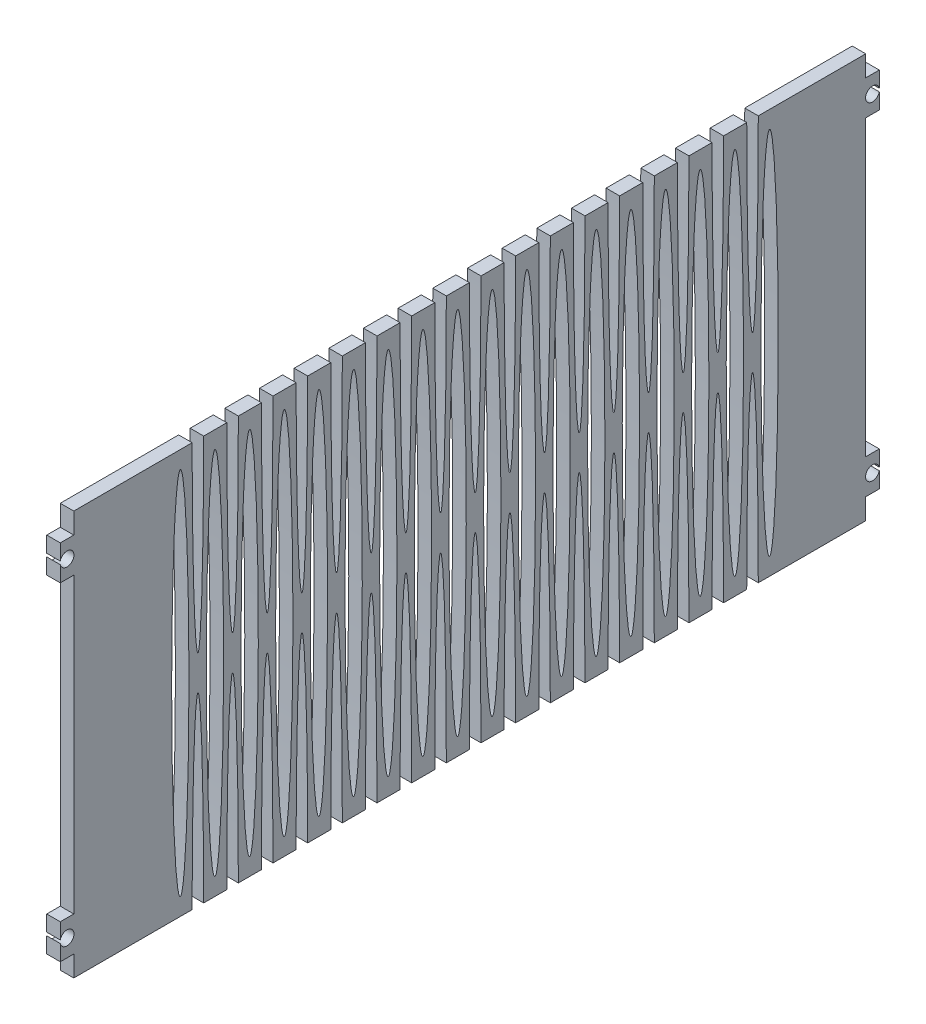
from build123d import *

# Parameters (mm, degrees)
SKETCH2_W             = 198.12
SKETCH2_H             = 88.9
BOSS_EXTRUDE1_DEPTH   = 2.9718
SKETCH3_RX            = 40.64
SKETCH3_RY            = 1.905
CUT_EXTRUDE1_DEPTH    = 3.9718
LPATTERN1_COUNT       = 18
LPATTERN1_PITCH       = 7.62
CUT_EXTRUDE2_DEPTH    = 3.9718001
LPATTERN2_COUNT       = 17
LPATTERN2_PITCH       = 7.62
MIRROR1_COPY_1_DEPTH  = 3.9718001
MIRROR1_COPY_2_DEPTH  = 3.9718001
MIRROR1_COPY_3_DEPTH  = 3.9718001
MIRROR1_COPY_4_DEPTH  = 3.9718001
MIRROR1_COPY_5_DEPTH  = 3.9718001
MIRROR1_COPY_6_DEPTH  = 3.9718001
MIRROR1_COPY_7_DEPTH  = 3.9718001
MIRROR1_COPY_8_DEPTH  = 3.9718001
MIRROR1_COPY_9_DEPTH  = 3.9718001
MIRROR1_COPY_10_DEPTH = 3.9718001
MIRROR1_COPY_11_DEPTH = 3.9718001
MIRROR1_COPY_12_DEPTH = 3.9718001
MIRROR1_COPY_13_DEPTH = 3.9718001
MIRROR1_COPY_14_DEPTH = 3.9718001
MIRROR1_COPY_15_DEPTH = 3.9718001
MIRROR1_COPY_16_DEPTH = 3.9718001
SKETCH5_W             = 48.694690428
SKETCH5_H             = 116.446098742
CUT_EXTRUDE3_DEPTH    = 3.9718001
SKETCH7_W             = 2.9718
SKETCH7_H             = 7.62
BOSS_EXTRUDE2_DEPTH   = 2.9718
SKETCH8_R             = 1.524
CUT_EXTRUDE4_DEPTH    = 3.9718001


with BuildPart() as part:
    # Sketch2 → Boss-Extrude1 (new body)
    with BuildSketch(Plane(origin=(0, 0, 0), x_dir=(0, 0, -1), z_dir=(1, 0, 0))):
        with Locations((99.06, 0)):
            Rectangle(SKETCH2_W, SKETCH2_H)
    extrude(amount=BOSS_EXTRUDE1_DEPTH)

    # Sketch3 → Cut-Extrude1 (cut, through all)
    with BuildSketch(Plane(origin=(2.9718, 0, 0), x_dir=(0, 0, -1), z_dir=(1, 0, 0))):
        with Locations(Location((47.434047001, 0), (0, 0, 90))):
            Ellipse(SKETCH3_RX, SKETCH3_RY)
    cut_extrude1 = extrude(amount=-CUT_EXTRUDE1_DEPTH, mode=Mode.SUBTRACT)

    # LPattern1: Cut-Extrude1 ×18
    with Locations(*[(0, 0, -i * LPATTERN1_PITCH) for i in range(1, LPATTERN1_COUNT)]):
        add(cut_extrude1, mode=Mode.SUBTRACT)

    # Sketch4 → Cut-Extrude2 (cut, through all)
    with BuildSketch(Plane(origin=(2.9718, 0, 0), x_dir=(0, 0, -1), z_dir=(1, 0, 0))):
        with BuildLine():
            Line((50.038, -44.45), (52.578, -44.45))
            add(Edge.make_bspline(
                [(52.578, -44.45), (52.578, -3.81), (51.308, -3.81), (50.038, -3.81), (50.038, -44.45)],
                knots=[4.71238898, 4.71238898, 4.71238898, 6.283185307, 6.283185307, 7.853981634, 7.853981634, 7.853981634], degree=2, weights=[1, 0.707106781, 1, 0.707106781, 1]))
        make_face()
    cut_extrude2 = extrude(amount=-CUT_EXTRUDE2_DEPTH, mode=Mode.SUBTRACT)

    # LPattern2: Cut-Extrude2 ×17
    with Locations(*[(0, 0, -i * LPATTERN2_PITCH) for i in range(1, LPATTERN2_COUNT)]):
        add(cut_extrude2, mode=Mode.SUBTRACT)

    # Mirror1: Cut-Extrude2 across plane
    add(cut_extrude2.mirror(Plane.ZX), mode=Mode.SUBTRACT)

    # Mirror1 copy 1 sketch → Mirror1 copy 1 (cut, through all)
    with BuildSketch(Plane(origin=(2.9718, 0, -7.62), x_dir=(0, 0, -1), z_dir=(1, 0, 0))):
        with BuildLine():
            Line((50.038, 44.45), (52.578, 44.45))
            add(Edge.make_bspline(
                [(52.578, 44.45), (52.578, 3.81), (51.308, 3.81), (50.038, 3.81), (50.038, 44.45)],
                knots=[4.71238898, 4.71238898, 4.71238898, 6.283185307, 6.283185307, 7.853981634, 7.853981634, 7.853981634], degree=2, weights=[1, 0.707106781, 1, 0.707106781, 1]))
        make_face()
    extrude(amount=-MIRROR1_COPY_1_DEPTH, mode=Mode.SUBTRACT)

    # Mirror1 copy 2 sketch → Mirror1 copy 2 (cut, through all)
    with BuildSketch(Plane(origin=(2.9718, 0, -15.24), x_dir=(0, 0, -1), z_dir=(1, 0, 0))):
        with BuildLine():
            Line((50.038, 44.45), (52.578, 44.45))
            add(Edge.make_bspline(
                [(52.578, 44.45), (52.578, 3.81), (51.308, 3.81), (50.038, 3.81), (50.038, 44.45)],
                knots=[4.71238898, 4.71238898, 4.71238898, 6.283185307, 6.283185307, 7.853981634, 7.853981634, 7.853981634], degree=2, weights=[1, 0.707106781, 1, 0.707106781, 1]))
        make_face()
    extrude(amount=-MIRROR1_COPY_2_DEPTH, mode=Mode.SUBTRACT)

    # Mirror1 copy 3 sketch → Mirror1 copy 3 (cut, through all)
    with BuildSketch(Plane(origin=(2.9718, 0, -22.86), x_dir=(0, 0, -1), z_dir=(1, 0, 0))):
        with BuildLine():
            Line((50.038, 44.45), (52.578, 44.45))
            add(Edge.make_bspline(
                [(52.578, 44.45), (52.578, 3.81), (51.308, 3.81), (50.038, 3.81), (50.038, 44.45)],
                knots=[4.71238898, 4.71238898, 4.71238898, 6.283185307, 6.283185307, 7.853981634, 7.853981634, 7.853981634], degree=2, weights=[1, 0.707106781, 1, 0.707106781, 1]))
        make_face()
    extrude(amount=-MIRROR1_COPY_3_DEPTH, mode=Mode.SUBTRACT)

    # Mirror1 copy 4 sketch → Mirror1 copy 4 (cut, through all)
    with BuildSketch(Plane(origin=(2.9718, 0, -30.48), x_dir=(0, 0, -1), z_dir=(1, 0, 0))):
        with BuildLine():
            Line((50.038, 44.45), (52.578, 44.45))
            add(Edge.make_bspline(
                [(52.578, 44.45), (52.578, 3.81), (51.308, 3.81), (50.038, 3.81), (50.038, 44.45)],
                knots=[4.71238898, 4.71238898, 4.71238898, 6.283185307, 6.283185307, 7.853981634, 7.853981634, 7.853981634], degree=2, weights=[1, 0.707106781, 1, 0.707106781, 1]))
        make_face()
    extrude(amount=-MIRROR1_COPY_4_DEPTH, mode=Mode.SUBTRACT)

    # Mirror1 copy 5 sketch → Mirror1 copy 5 (cut, through all)
    with BuildSketch(Plane(origin=(2.9718, 0, -38.1), x_dir=(0, 0, -1), z_dir=(1, 0, 0))):
        with BuildLine():
            Line((50.038, 44.45), (52.578, 44.45))
            add(Edge.make_bspline(
                [(52.578, 44.45), (52.578, 3.81), (51.308, 3.81), (50.038, 3.81), (50.038, 44.45)],
                knots=[4.71238898, 4.71238898, 4.71238898, 6.283185307, 6.283185307, 7.853981634, 7.853981634, 7.853981634], degree=2, weights=[1, 0.707106781, 1, 0.707106781, 1]))
        make_face()
    extrude(amount=-MIRROR1_COPY_5_DEPTH, mode=Mode.SUBTRACT)

    # Mirror1 copy 6 sketch → Mirror1 copy 6 (cut, through all)
    with BuildSketch(Plane(origin=(2.9718, 0, -45.72), x_dir=(0, 0, -1), z_dir=(1, 0, 0))):
        with BuildLine():
            Line((50.038, 44.45), (52.578, 44.45))
            add(Edge.make_bspline(
                [(52.578, 44.45), (52.578, 3.81), (51.308, 3.81), (50.038, 3.81), (50.038, 44.45)],
                knots=[4.71238898, 4.71238898, 4.71238898, 6.283185307, 6.283185307, 7.853981634, 7.853981634, 7.853981634], degree=2, weights=[1, 0.707106781, 1, 0.707106781, 1]))
        make_face()
    extrude(amount=-MIRROR1_COPY_6_DEPTH, mode=Mode.SUBTRACT)

    # Mirror1 copy 7 sketch → Mirror1 copy 7 (cut, through all)
    with BuildSketch(Plane(origin=(2.9718, 0, -53.34), x_dir=(0, 0, -1), z_dir=(1, 0, 0))):
        with BuildLine():
            Line((50.038, 44.45), (52.578, 44.45))
            add(Edge.make_bspline(
                [(52.578, 44.45), (52.578, 3.81), (51.308, 3.81), (50.038, 3.81), (50.038, 44.45)],
                knots=[4.71238898, 4.71238898, 4.71238898, 6.283185307, 6.283185307, 7.853981634, 7.853981634, 7.853981634], degree=2, weights=[1, 0.707106781, 1, 0.707106781, 1]))
        make_face()
    extrude(amount=-MIRROR1_COPY_7_DEPTH, mode=Mode.SUBTRACT)

    # Mirror1 copy 8 sketch → Mirror1 copy 8 (cut, through all)
    with BuildSketch(Plane(origin=(2.9718, 0, -60.96), x_dir=(0, 0, -1), z_dir=(1, 0, 0))):
        with BuildLine():
            Line((50.038, 44.45), (52.578, 44.45))
            add(Edge.make_bspline(
                [(52.578, 44.45), (52.578, 3.81), (51.308, 3.81), (50.038, 3.81), (50.038, 44.45)],
                knots=[4.71238898, 4.71238898, 4.71238898, 6.283185307, 6.283185307, 7.853981634, 7.853981634, 7.853981634], degree=2, weights=[1, 0.707106781, 1, 0.707106781, 1]))
        make_face()
    extrude(amount=-MIRROR1_COPY_8_DEPTH, mode=Mode.SUBTRACT)

    # Mirror1 copy 9 sketch → Mirror1 copy 9 (cut, through all)
    with BuildSketch(Plane(origin=(2.9718, 0, -68.58), x_dir=(0, 0, -1), z_dir=(1, 0, 0))):
        with BuildLine():
            Line((50.038, 44.45), (52.578, 44.45))
            add(Edge.make_bspline(
                [(52.578, 44.45), (52.578, 3.81), (51.308, 3.81), (50.038, 3.81), (50.038, 44.45)],
                knots=[4.71238898, 4.71238898, 4.71238898, 6.283185307, 6.283185307, 7.853981634, 7.853981634, 7.853981634], degree=2, weights=[1, 0.707106781, 1, 0.707106781, 1]))
        make_face()
    extrude(amount=-MIRROR1_COPY_9_DEPTH, mode=Mode.SUBTRACT)

    # Mirror1 copy 10 sketch → Mirror1 copy 10 (cut, through all)
    with BuildSketch(Plane(origin=(2.9718, 0, -76.2), x_dir=(0, 0, -1), z_dir=(1, 0, 0))):
        with BuildLine():
            Line((50.038, 44.45), (52.578, 44.45))
            add(Edge.make_bspline(
                [(52.578, 44.45), (52.578, 3.81), (51.308, 3.81), (50.038, 3.81), (50.038, 44.45)],
                knots=[4.71238898, 4.71238898, 4.71238898, 6.283185307, 6.283185307, 7.853981634, 7.853981634, 7.853981634], degree=2, weights=[1, 0.707106781, 1, 0.707106781, 1]))
        make_face()
    extrude(amount=-MIRROR1_COPY_10_DEPTH, mode=Mode.SUBTRACT)

    # Mirror1 copy 11 sketch → Mirror1 copy 11 (cut, through all)
    with BuildSketch(Plane(origin=(2.9718, 0, -83.82), x_dir=(0, 0, -1), z_dir=(1, 0, 0))):
        with BuildLine():
            Line((50.038, 44.45), (52.578, 44.45))
            add(Edge.make_bspline(
                [(52.578, 44.45), (52.578, 3.81), (51.308, 3.81), (50.038, 3.81), (50.038, 44.45)],
                knots=[4.71238898, 4.71238898, 4.71238898, 6.283185307, 6.283185307, 7.853981634, 7.853981634, 7.853981634], degree=2, weights=[1, 0.707106781, 1, 0.707106781, 1]))
        make_face()
    extrude(amount=-MIRROR1_COPY_11_DEPTH, mode=Mode.SUBTRACT)

    # Mirror1 copy 12 sketch → Mirror1 copy 12 (cut, through all)
    with BuildSketch(Plane(origin=(2.9718, 0, -91.44), x_dir=(0, 0, -1), z_dir=(1, 0, 0))):
        with BuildLine():
            Line((50.038, 44.45), (52.578, 44.45))
            add(Edge.make_bspline(
                [(52.578, 44.45), (52.578, 3.81), (51.308, 3.81), (50.038, 3.81), (50.038, 44.45)],
                knots=[4.71238898, 4.71238898, 4.71238898, 6.283185307, 6.283185307, 7.853981634, 7.853981634, 7.853981634], degree=2, weights=[1, 0.707106781, 1, 0.707106781, 1]))
        make_face()
    extrude(amount=-MIRROR1_COPY_12_DEPTH, mode=Mode.SUBTRACT)

    # Mirror1 copy 13 sketch → Mirror1 copy 13 (cut, through all)
    with BuildSketch(Plane(origin=(2.9718, 0, -99.06), x_dir=(0, 0, -1), z_dir=(1, 0, 0))):
        with BuildLine():
            Line((50.038, 44.45), (52.578, 44.45))
            add(Edge.make_bspline(
                [(52.578, 44.45), (52.578, 3.81), (51.308, 3.81), (50.038, 3.81), (50.038, 44.45)],
                knots=[4.71238898, 4.71238898, 4.71238898, 6.283185307, 6.283185307, 7.853981634, 7.853981634, 7.853981634], degree=2, weights=[1, 0.707106781, 1, 0.707106781, 1]))
        make_face()
    extrude(amount=-MIRROR1_COPY_13_DEPTH, mode=Mode.SUBTRACT)

    # Mirror1 copy 14 sketch → Mirror1 copy 14 (cut, through all)
    with BuildSketch(Plane(origin=(2.9718, 0, -106.68), x_dir=(0, 0, -1), z_dir=(1, 0, 0))):
        with BuildLine():
            Line((50.038, 44.45), (52.578, 44.45))
            add(Edge.make_bspline(
                [(52.578, 44.45), (52.578, 3.81), (51.308, 3.81), (50.038, 3.81), (50.038, 44.45)],
                knots=[4.71238898, 4.71238898, 4.71238898, 6.283185307, 6.283185307, 7.853981634, 7.853981634, 7.853981634], degree=2, weights=[1, 0.707106781, 1, 0.707106781, 1]))
        make_face()
    extrude(amount=-MIRROR1_COPY_14_DEPTH, mode=Mode.SUBTRACT)

    # Mirror1 copy 15 sketch → Mirror1 copy 15 (cut, through all)
    with BuildSketch(Plane(origin=(2.9718, 0, -114.3), x_dir=(0, 0, -1), z_dir=(1, 0, 0))):
        with BuildLine():
            Line((50.038, 44.45), (52.578, 44.45))
            add(Edge.make_bspline(
                [(52.578, 44.45), (52.578, 3.81), (51.308, 3.81), (50.038, 3.81), (50.038, 44.45)],
                knots=[4.71238898, 4.71238898, 4.71238898, 6.283185307, 6.283185307, 7.853981634, 7.853981634, 7.853981634], degree=2, weights=[1, 0.707106781, 1, 0.707106781, 1]))
        make_face()
    extrude(amount=-MIRROR1_COPY_15_DEPTH, mode=Mode.SUBTRACT)

    # Mirror1 copy 16 sketch → Mirror1 copy 16 (cut, through all)
    with BuildSketch(Plane(origin=(2.9718, 0, -121.92), x_dir=(0, 0, -1), z_dir=(1, 0, 0))):
        with BuildLine():
            Line((50.038, 44.45), (52.578, 44.45))
            add(Edge.make_bspline(
                [(52.578, 44.45), (52.578, 3.81), (51.308, 3.81), (50.038, 3.81), (50.038, 44.45)],
                knots=[4.71238898, 4.71238898, 4.71238898, 6.283185307, 6.283185307, 7.853981634, 7.853981634, 7.853981634], degree=2, weights=[1, 0.707106781, 1, 0.707106781, 1]))
        make_face()
    extrude(amount=-MIRROR1_COPY_16_DEPTH, mode=Mode.SUBTRACT)

    # Sketch5 → Cut-Extrude3 (cut, through all)
    with BuildSketch(Plane(origin=(2.9718, 0, 0), x_dir=(0, 0, -1), z_dir=(1, 0, 0))):
        with Locations((-0.332546778, 1.201431204)):
            Rectangle(SKETCH5_W, SKETCH5_H)
    extrude(amount=-CUT_EXTRUDE3_DEPTH, mode=Mode.SUBTRACT)

    # Sketch7 → Boss-Extrude2 (add)
    with BuildSketch(Plane(origin=(0, 0, 0), x_dir=(0, 0, -1), z_dir=(1, 0, 0))):
        with Locations((22.528898436, 36.068)):
            Rectangle(SKETCH7_W, SKETCH7_H)
        with Locations((199.6059, 36.068)):
            Rectangle(SKETCH7_W, SKETCH7_H)
        with Locations((199.6059, -36.068)):
            Rectangle(SKETCH7_W, SKETCH7_H)
        with Locations((22.528898436, -36.068)):
            Rectangle(SKETCH7_W, SKETCH7_H)
    extrude(amount=BOSS_EXTRUDE2_DEPTH)

    # Sketch8 → Cut-Extrude4 (cut, through all)
    with BuildSketch(Plane(origin=(2.9718, 0, 0), x_dir=(0, 0, -1), z_dir=(1, 0, 0))):
        with Locations((22.528898436, 36.068)):
            Circle(SKETCH8_R)
        with Locations((199.6059, 36.068)):
            Circle(SKETCH8_R)
        with Locations((199.6059, -36.068)):
            Circle(SKETCH8_R)
        with Locations((22.528898436, -36.068)):
            Circle(SKETCH8_R)
    extrude(amount=-CUT_EXTRUDE4_DEPTH, mode=Mode.SUBTRACT)


solid = part.part
